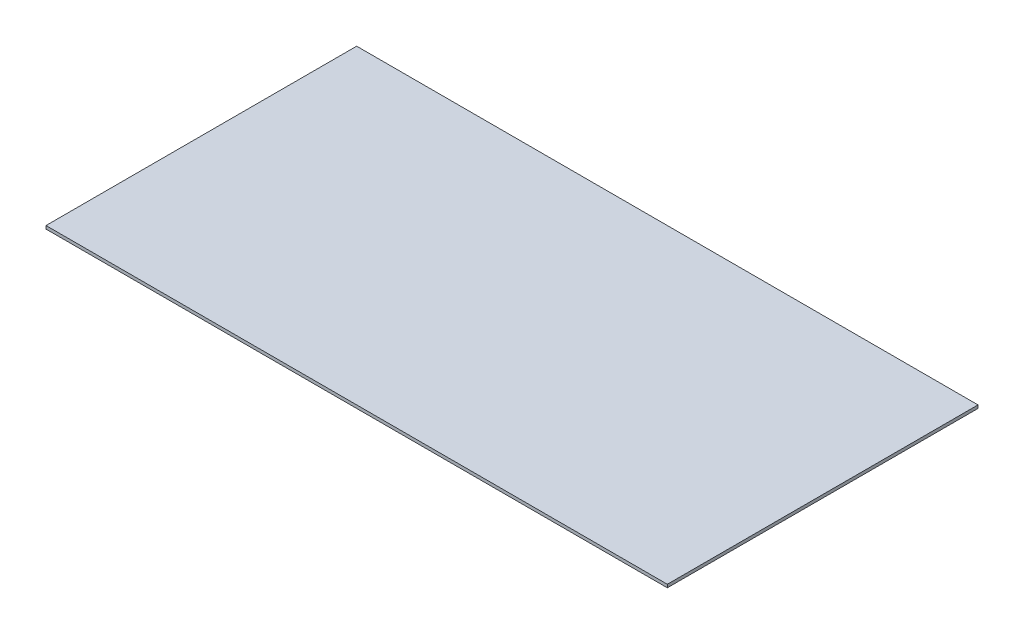
from build123d import *

# Parameters (mm, degrees)
CROQUIS1_W              = 2000
CROQUIS1_H              = 1000
SALIENTE_EXTRUIR1_DEPTH = 10


with BuildPart() as part:
    # Croquis1 → Saliente-Extruir1 (new body)
    with BuildSketch(Plane(origin=(0, 0, 0), x_dir=(1, 0, 0), z_dir=(0, 1, 0))):
        Rectangle(CROQUIS1_W, CROQUIS1_H)
    extrude(amount=SALIENTE_EXTRUIR1_DEPTH)


solid = part.part
